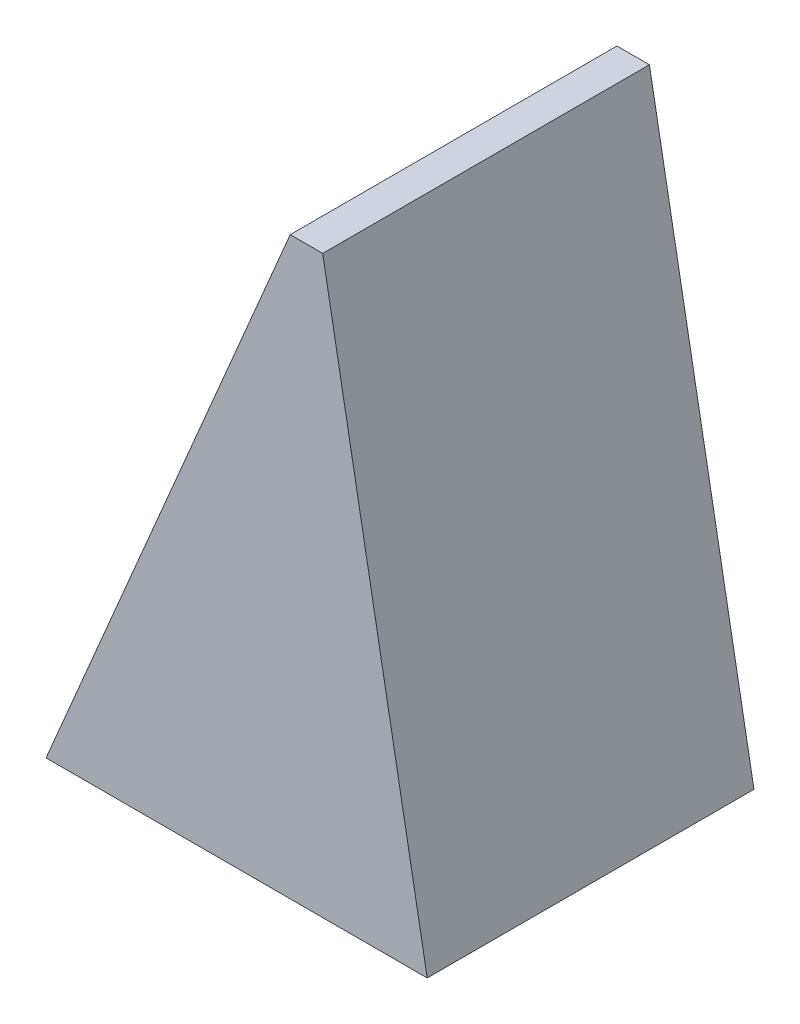
from build123d import *

# Parameters (mm, degrees)
BOSS_EXTRUDE1_DEPTH = 0.6
CHAMFER1_SIZE       = 0.1
CHAMFER1_SIZE2      = 0.106885372


with BuildPart() as part:
    # Sketch1 → Boss-Extrude1 (new body)
    with BuildSketch(Plane.XY):
        Polygon((0, 0), (0.7, 0), (0.490151136, 1.154723713), align=None)
    extrude(amount=BOSS_EXTRUDE1_DEPTH)

    # Chamfer1
    chamfer1_edges = [part.edges().sort_by_distance(p)[0] for p in [
        (0.490151136, 1.154723713, 0.3),
    ]]
    chamfer1_side = [part.faces().sort_by_distance(p)[0] for p in [
        (0.595075568, 0.577361856, 0.3),
    ]]
    chamfer(chamfer1_edges, length=CHAMFER1_SIZE, length2=CHAMFER1_SIZE2, reference=chamfer1_side[0])


solid = part.part
